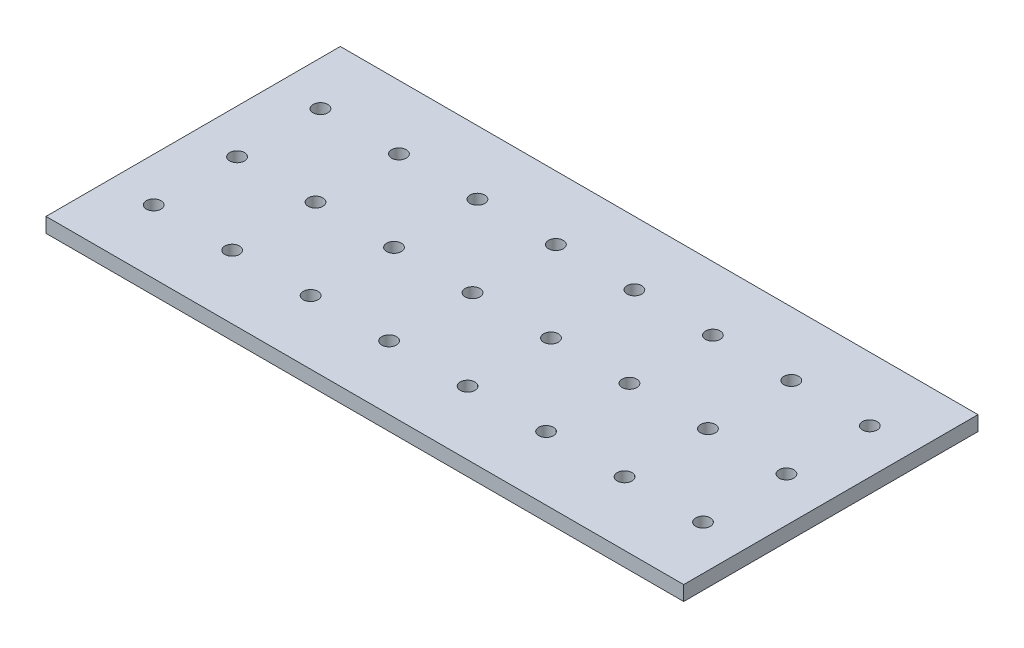
from build123d import *

# Parameters (mm, degrees)
SKETCH_1_W          = 130
SKETCH_1_H          = 60
EXTRUDE_1_DEPTH     = 3
SKETCH_2_R          = 1.5
CUT_EXTRUDE_1_DEPTH = 3


with BuildPart() as part:
    # Эскиз1 → Бобышка-Вытянуть1 (new body)
    with BuildSketch(Plane(origin=(0, 0, 0), x_dir=(1, 0, 0), z_dir=(0, 1, 0))):
        Rectangle(SKETCH_1_W, SKETCH_1_H)
    extrude(amount=EXTRUDE_1_DEPTH)

    # Эскиз2 → Вырез-Вытянуть1 (cut)
    with BuildSketch(Plane(origin=(0, 3, 0), x_dir=(1, 0, 0), z_dir=(0, 1, 0))):
        with Locations((-56.052735869, 17)):
            Circle(SKETCH_2_R)
        with Locations((-40.052735869, 17)):
            Circle(SKETCH_2_R)
        with Locations((-24.052735869, 17)):
            Circle(SKETCH_2_R)
        with Locations((-8.052735869, 17)):
            Circle(SKETCH_2_R)
        with Locations((7.947264131, 17)):
            Circle(SKETCH_2_R)
        with Locations((23.947264131, 17)):
            Circle(SKETCH_2_R)
        with Locations((39.947264131, 17)):
            Circle(SKETCH_2_R)
        with Locations((55.947264131, 17)):
            Circle(SKETCH_2_R)
        with Locations((-56.052735869, 0)):
            Circle(SKETCH_2_R)
        with Locations((-56.052735869, -17)):
            Circle(SKETCH_2_R)
        with Locations((-40.052735869, 0)):
            Circle(SKETCH_2_R)
        with Locations((-40.052735869, -17)):
            Circle(SKETCH_2_R)
        with Locations((-24.052735869, 0)):
            Circle(SKETCH_2_R)
        with Locations((-24.052735869, -17)):
            Circle(SKETCH_2_R)
        with Locations((-8.052735869, 0)):
            Circle(SKETCH_2_R)
        with Locations((-8.052735869, -17)):
            Circle(SKETCH_2_R)
        with Locations((7.947264131, 0)):
            Circle(SKETCH_2_R)
        with Locations((7.947264131, -17)):
            Circle(SKETCH_2_R)
        with Locations((23.947264131, 0)):
            Circle(SKETCH_2_R)
        with Locations((23.947264131, -17)):
            Circle(SKETCH_2_R)
        with Locations((39.947264131, 0)):
            Circle(SKETCH_2_R)
        with Locations((39.947264131, -17)):
            Circle(SKETCH_2_R)
        with Locations((55.947264131, 0)):
            Circle(SKETCH_2_R)
        with Locations((55.947264131, -17)):
            Circle(SKETCH_2_R)
    extrude(amount=-CUT_EXTRUDE_1_DEPTH, mode=Mode.SUBTRACT)


solid = part.part
